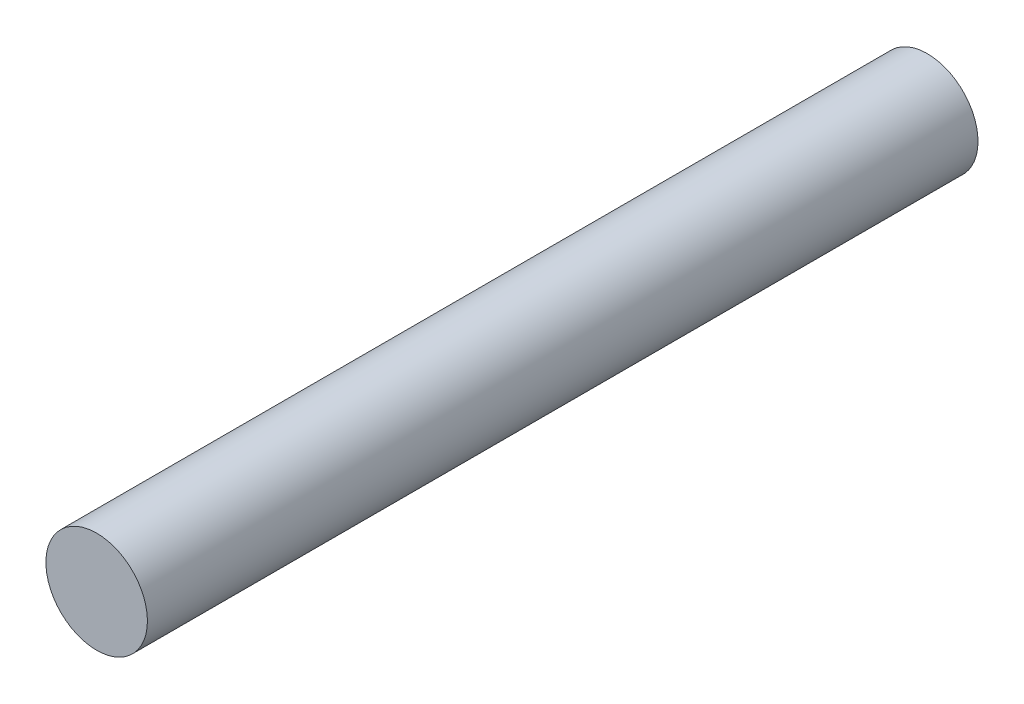
from build123d import *

# Parameters (mm, degrees)
SKETCH1_R           = 5.5
BOSS_EXTRUDE1_DEPTH = 90


with BuildPart() as part:
    # Sketch1 → Boss-Extrude1 (new body)
    with BuildSketch(Plane.XY):
        Circle(SKETCH1_R)
    extrude(amount=BOSS_EXTRUDE1_DEPTH)


solid = part.part
